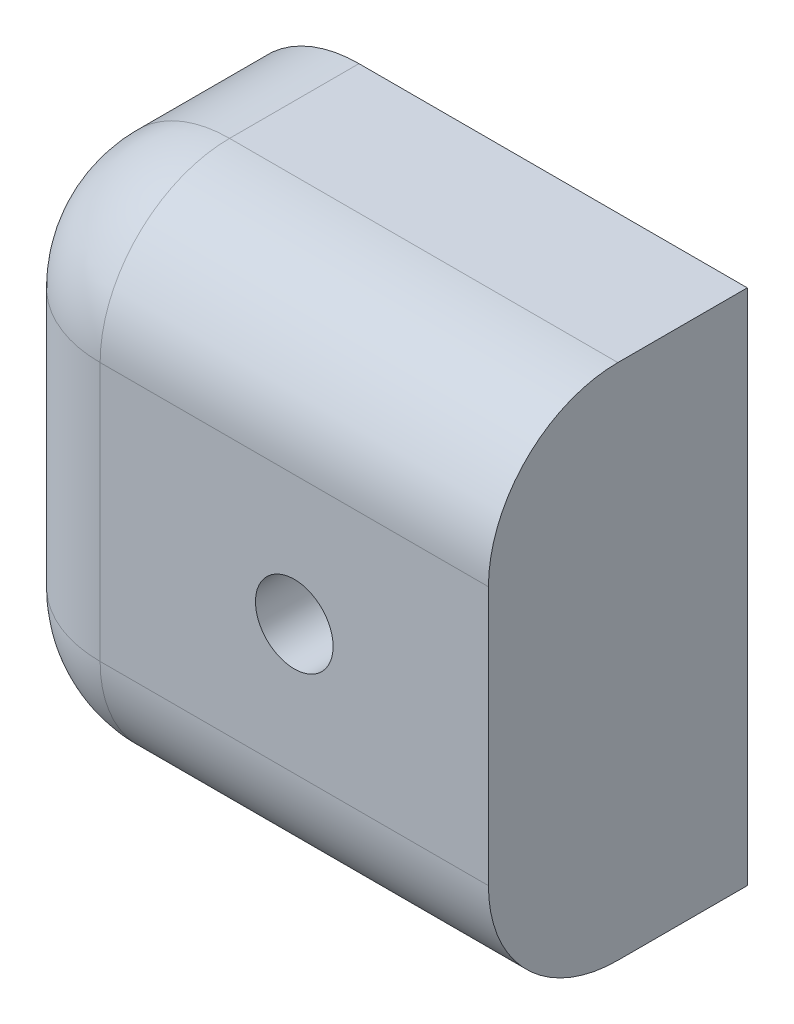
from build123d import *

# Parameters (mm, degrees)
BOSS_EXTRU_1_DEPTH      = 10
CONG_1_R                = 5
ESQUISSE2_R             = 1.5
ENL_V_MAT_EXTRU_1_DEPTH = 10


with BuildPart() as part:
    # Esquisse1 → Boss.-Extru.1 (new body)
    with BuildSketch(Plane.XY):
        with BuildLine():
            Line((5, 0), (20, 0))
            Line((20, 0), (20, 20))
            Line((20, 20), (5, 20))
            ThreePointArc((5, 20), (1.464466094, 18.535533906), (0, 15))
            Line((0, 15), (0, 5))
            ThreePointArc((0, 5), (1.464466094, 1.464466094), (5, 0))
        make_face()
    extrude(amount=BOSS_EXTRU_1_DEPTH)

    # Congé1
    cong_1_edges = [part.edges().sort_by_distance(p)[0] for p in [
        (12.5, 20, 10),
        (1.464466094, 18.535533906, 10),
        (0, 10, 10),
        (12.5, 0, 10),
        (1.464466094, 1.464466094, 10),
    ]]
    fillet(cong_1_edges, radius=CONG_1_R)

    # Esquisse2 → Enlèv. mat.-Extru.1 (cut)
    with BuildSketch(Plane.XY.offset(10)):
        with Locations((12.5, 10)):
            Circle(ESQUISSE2_R)
    extrude(amount=-ENL_V_MAT_EXTRU_1_DEPTH, mode=Mode.SUBTRACT)


solid = part.part
